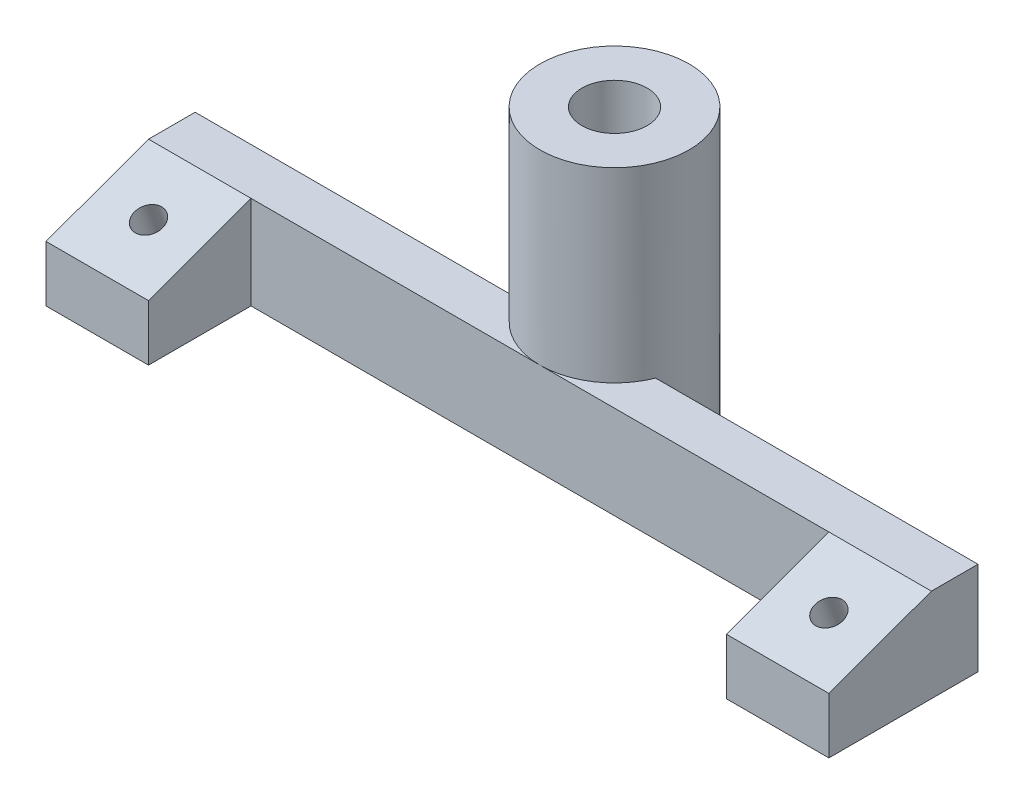
from build123d import *

# Parameters (mm, degrees)
EXTRUDE_1_DEPTH     = 10
CUT_EXTRUDE_4_DEPTH = 85
SKETCH_6_R          = 1.5
CUT_EXTRUDE_5_DEPTH = 12.107026924
SKETCH_7_R          = 3.25
CUT_EXTRUDE_6_DEPTH = 8.107026924
SKETCH_8_R          = 8
EXTRUDE_2_DEPTH     = 30
SKETCH_9_R          = 3.5
CUT_EXTRUDE_7_DEPTH = 30
SKETCH_10_R         = 5.25
CUT_EXTRUDE_8_DEPTH = 24


with BuildPart() as part:
    # 草图1 → 凸台-拉伸1 (new body)
    with BuildSketch(Plane(origin=(0, 0, 0), x_dir=(1, 0, 0), z_dir=(0, 1, 0))):
        Polygon((-42, 5.5), (-42, 10.5), (42, 10.5), (42, 5.5), (42, -5.5), (31, -5.5), (31, 5.5), (-31, 5.5), (-31, -5.5), (-42, -5.5), align=None)
    extrude(amount=EXTRUDE_1_DEPTH)

    # 草图5 → 切除-拉伸4 (cut, through all)
    with BuildSketch(Plane.ZY.offset(42)):
        Polygon((-5.5, 10), (5.5, 5.996327423), (5.5, 10), align=None)
    extrude(amount=-CUT_EXTRUDE_4_DEPTH, mode=Mode.SUBTRACT)

    # 草图6 → 切除-拉伸5 (cut, through all)
    with BuildSketch(Plane(origin=(0, 13.15030494, -14.155391688), x_dir=(1, 0, 0), z_dir=(0, -0.939692621, -0.342020143))):
        with Locations((-36.5, 15.063853195)):
            Circle(SKETCH_6_R)
        with Locations((36.5, 15.063853195)):
            Circle(SKETCH_6_R)
    extrude(amount=CUT_EXTRUDE_5_DEPTH, mode=Mode.SUBTRACT)

    # 草图7 → 切除-拉伸6 (cut, through all)
    with BuildSketch(Plane(origin=(0, 3.303785806, 1.202479694), x_dir=(1, 0, 0), z_dir=(0, 0.939692621, 0.342020143))):
        with Locations((-36.5, 2.735533099)):
            Circle(SKETCH_7_R)
        with Locations((36.5, 2.735533099)):
            Circle(SKETCH_7_R)
    extrude(amount=-CUT_EXTRUDE_6_DEPTH, mode=Mode.SUBTRACT)

    # 草图8 → 凸台-拉伸2 (add)
    with BuildSketch(Plane.XZ):
        with Locations((0, -13.5)):
            Circle(SKETCH_8_R)
    extrude(amount=-EXTRUDE_2_DEPTH)

    # 草图9 → 切除-拉伸7 (cut)
    with BuildSketch(Plane(origin=(0, 30, 0), x_dir=(1, 0, 0), z_dir=(0, 1, 0))):
        with Locations((0, 13.5)):
            Circle(SKETCH_9_R)
    extrude(amount=-CUT_EXTRUDE_7_DEPTH, mode=Mode.SUBTRACT)

    # 草图10 → 切除-拉伸8 (cut)
    with BuildSketch(Plane.XZ):
        with Locations((0, -13.5)):
            Circle(SKETCH_10_R)
    extrude(amount=-CUT_EXTRUDE_8_DEPTH, mode=Mode.SUBTRACT)


solid = part.part
